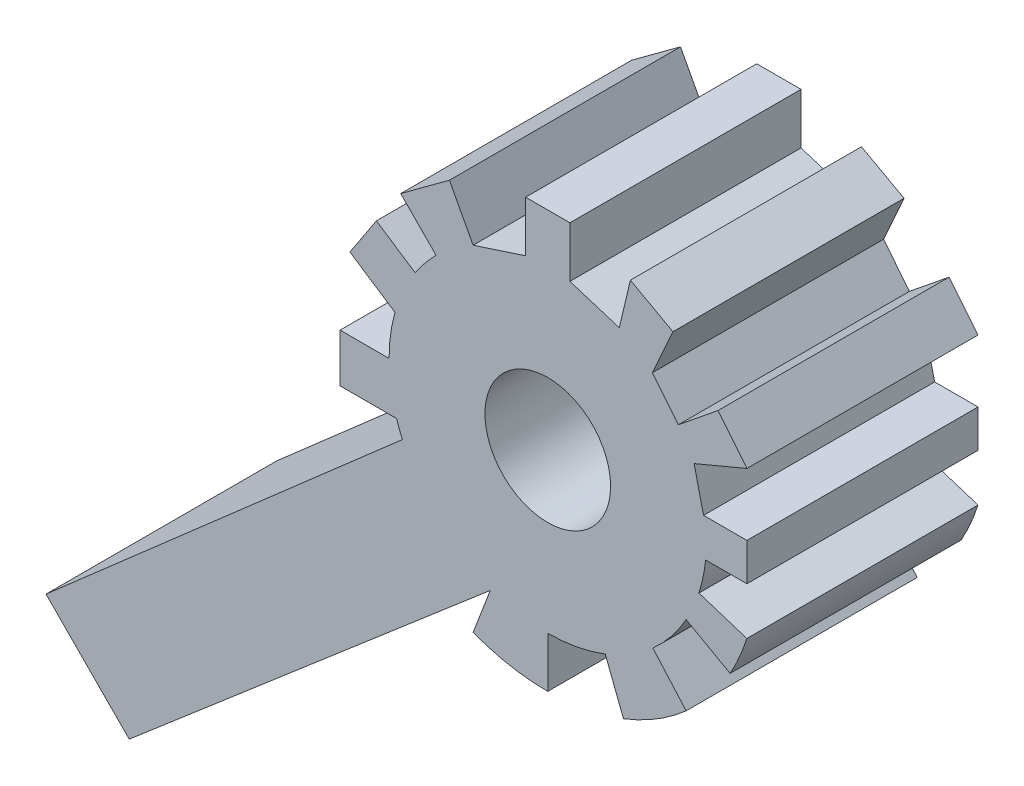
from build123d import *

# Parameters (mm, degrees)
SKETCH1_R           = 2.718976156
BOSS_EXTRUDE1_DEPTH = 5


with BuildPart() as part:
    # Sketch1 → Boss-Extrude1 (new body, symmetric)
    with BuildSketch(Plane.XY):
        with BuildLine():
            Line((-71.230316372, 16.423183965), (-69.697125978, 14.874544766))
            ThreePointArc((-69.697125978, 14.874544766), (-70.178618015, 14.345414894), (-70.602445452, 13.769061439))
            Line((-70.602445452, 13.769061439), (-72.282613853, 14.874544766))
            Line((-72.282613853, 14.874544766), (-73.429019542, 13.132180531))
            Line((-73.429019542, 13.132180531), (-71.477844105, 11.848385459))
            ThreePointArc((-71.477844105, 11.848385459), (-71.668751879, 10.930245938), (-71.732785885, 9.994657565))
            Line((-71.732785885, 9.994657565), (-73.852173913, 9.994657565))
            Line((-73.852173913, 9.994657565), (-73.852173913, 7.904409303))
            Line((-73.852173913, 7.904409303), (-71.406922201, 7.904409303))
            ThreePointArc((-71.406922201, 7.904409303), (-71.290285788, 7.56950355), (-71.156514693, 7.24106602))
            Line((-71.156514693, 7.24106602), (-86.578147363, -6.260758332))
            Line((-86.578147363, -6.260758332), (-82.977208325, -9.89798132))
            Line((-82.977208325, -9.89798132), (-67.353165307, 3.488554168))
            Line((-67.353165307, 3.488554168), (-68.096179637, 1.544987721))
            ThreePointArc((-68.096179637, 1.544987721), (-66.508347558, 1.098932073), (-64.865919209, 0.948580907))
            Line((-64.865919209, 0.948580907), (-64.865919209, 3.127790889))
            ThreePointArc((-64.865919209, 3.127790889), (-63.601066667, 3.24528678), (-62.37949878, 3.593753614))
            Line((-62.37949878, 3.593753614), (-61.590429693, 1.562417569))
            ThreePointArc((-61.590429693, 1.562417569), (-60.160877534, 2.268462787), (-58.877488851, 3.214524472))
            Line((-58.877488851, 3.214524472), (-60.320108421, 4.847866116))
            ThreePointArc((-60.320108421, 4.847866116), (-59.523604951, 5.680316792), (-58.877488851, 6.634217149))
            Line((-58.877488851, 6.634217149), (-56.977051893, 5.567776566))
            ThreePointArc((-56.977051893, 5.567776566), (-56.570785994, 6.386019614), (-56.249119541, 7.24106602))
            Line((-56.249119541, 7.24106602), (-58.324916217, 7.904409303))
            ThreePointArc((-58.324916217, 7.904409303), (-58.144259528, 8.589969318), (-58.035251347, 9.290502395))
            Line((-58.035251347, 9.290502395), (-56.249119541, 9.290502395))
            Line((-56.249119541, 9.290502395), (-56.249119541, 10.916483695))
            Line((-56.249119541, 10.916483695), (-58.125115153, 10.916483695))
            Line((-58.125115153, 10.916483695), (-58.534150947, 12.652206929))
            Line((-58.534150947, 12.652206929), (-56.249119541, 13.611272945))
            Line((-56.249119541, 13.611272945), (-57.500945462, 15.156219029))
            Line((-57.500945462, 15.156219029), (-59.21291168, 13.769061439))
            Line((-59.21291168, 13.769061439), (-60.336886068, 15.156219029))
            Line((-60.336886068, 15.156219029), (-59.44992841, 17.136193302))
            Line((-59.44992841, 17.136193302), (-61.290349947, 18.148130182))
            Line((-61.290349947, 18.148130182), (-61.770458694, 16.124256422))
            Line((-61.770458694, 16.124256422), (-63.907050908, 16.794247959))
            Line((-63.907050908, 16.794247959), (-63.907050908, 18.989771489))
            Line((-63.907050908, 18.989771489), (-65.82478751, 18.989771489))
            Line((-65.82478751, 18.989771489), (-65.82478751, 16.794247959))
            Line((-65.82478751, 16.794247959), (-68.096179637, 16.054300748))
            Line((-68.096179637, 16.054300748), (-69.121307415, 17.977337199))
            Line((-69.121307415, 17.977337199), (-71.230316372, 16.423183965))
        make_face()
        with Locations((-64.865919209, 9.994657565)):
            Circle(SKETCH1_R, mode=Mode.SUBTRACT)
    extrude(amount=BOSS_EXTRUDE1_DEPTH, both=True)


solid = part.part
